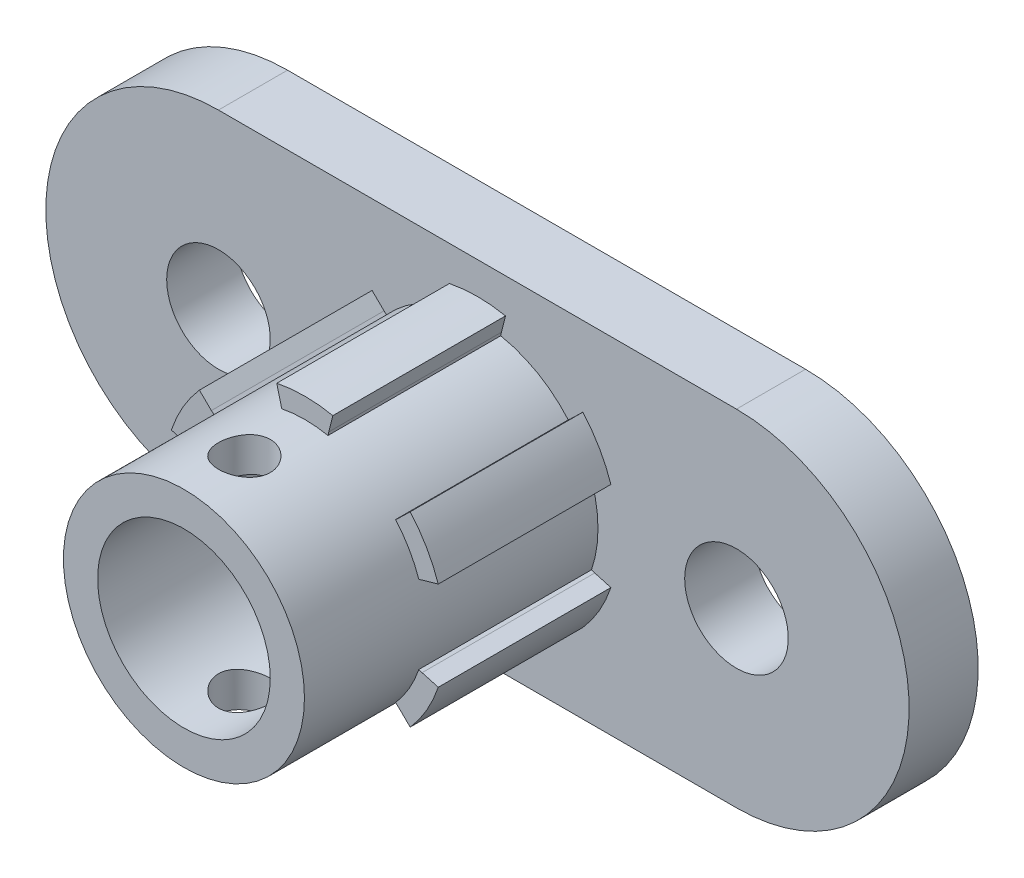
from build123d import *

# Parameters (mm, degrees)
BOSS_EXTRUDE1_DEPTH = 10
SKETCH4_R           = 3
BOSS_EXTRUDE2_DEPTH = 4
CUT_EXTRUDE2_DEPTH  = 10
SKETCH9_R           = 5
CUT_EXTRUDE3_DEPTH  = 15
SKETCH10_R          = 6.98
SKETCH10_R_2        = 5
BOSS_EXTRUDE3_DEPTH = 7
SKETCH11_R          = 1.5
CUT_EXTRUDE4_DEPTH  = 21


with BuildPart() as part:
    # Sketch3 → Boss-Extrude1 (new body)
    with BuildSketch(Plane.XY):
        with BuildLine():
            Line((-7.72865, 2.586593), (-6.793519, 2.323899))
            ThreePointArc((-6.793519, 2.323899), (-7.18, 0), (-6.793519, -2.323899))
            Line((-6.793519, -2.323899), (-7.72865, -2.586593))
            ThreePointArc((-7.72865, -2.586593), (-7.058107, -4.075), (-6.104381, -5.399911))
            Line((-6.104381, -5.399911), (-5.409315, -4.72141))
            ThreePointArc((-5.409315, -4.72141), (-3.59, -6.218062), (-1.384204, -7.045309))
            Line((-1.384204, -7.045309), (-1.62427, -7.986504))
            ThreePointArc((-1.62427, -7.986504), (0, -8.15), (1.62427, -7.986504))
            Line((1.62427, -7.986504), (1.384204, -7.045309))
            ThreePointArc((1.384204, -7.045309), (3.59, -6.218062), (5.409315, -4.72141))
            Line((5.409315, -4.72141), (6.104381, -5.399911))
            ThreePointArc((6.104381, -5.399911), (7.058107, -4.075), (7.72865, -2.586593))
            Line((7.72865, -2.586593), (6.793519, -2.323899))
            ThreePointArc((6.793519, -2.323899), (7.18, 0), (6.793519, 2.323899))
            Line((6.793519, 2.323899), (7.72865, 2.586593))
            ThreePointArc((7.72865, 2.586593), (7.058107, 4.075), (6.104381, 5.399911))
            Line((6.104381, 5.399911), (5.409315, 4.72141))
            ThreePointArc((5.409315, 4.72141), (3.59, 6.218062), (1.384204, 7.045309))
            Line((1.384204, 7.045309), (1.62427, 7.986504))
            ThreePointArc((1.62427, 7.986504), (0, 8.15), (-1.62427, 7.986504))
            Line((-1.62427, 7.986504), (-1.384204, 7.045309))
            ThreePointArc((-1.384204, 7.045309), (-3.59, 6.218062), (-5.409315, 4.72141))
            Line((-5.409315, 4.72141), (-6.104381, 5.399911))
            ThreePointArc((-6.104381, 5.399911), (-7.058107, 4.075), (-7.72865, 2.586593))
        make_face()
    extrude(amount=BOSS_EXTRUDE1_DEPTH)

    # Sketch4 → Boss-Extrude2 (add)
    with BuildSketch(Plane(origin=(0, 0, 0), x_dir=(-1, 0, 0), z_dir=(0, 0, -1))):
        with BuildLine():
            Line((-15, 10), (15, 10))
            ThreePointArc((15, 10), (25, 0), (15, -10))
            Line((15, -10), (-15, -10))
            ThreePointArc((-15, -10), (-25, 0), (-15, 10))
        make_face()
        with Locations((-15, 0)):
            Circle(SKETCH4_R, mode=Mode.SUBTRACT)
        with Locations((15, 0)):
            Circle(SKETCH4_R, mode=Mode.SUBTRACT)
    extrude(amount=BOSS_EXTRUDE2_DEPTH)

    # Sketch8 → Cut-Extrude2 (cut)
    with BuildSketch(Plane.XY.offset(10)):
        with BuildLine():
            Line((-5.409315, 4.72141), (-5.258637, 4.589895))
            ThreePointArc((-5.258637, 4.589895), (-3.49, 6.044857), (-1.345647, 6.849061))
            Line((-1.345647, 6.849061), (-1.384204, 7.045309))
            ThreePointArc((-1.384204, 7.045309), (-3.59, 6.218062), (-5.409315, 4.72141))
        make_face()
        with BuildLine():
            Line((5.409315, 4.72141), (5.258637, 4.589895))
            ThreePointArc((5.258637, 4.589895), (3.49, 6.044857), (1.345647, 6.849061))
            Line((1.345647, 6.849061), (1.384204, 7.045309))
            ThreePointArc((1.384204, 7.045309), (3.59, 6.218062), (5.409315, 4.72141))
        make_face()
        with BuildLine():
            Line((6.793519, -2.323899), (6.604284, -2.259166))
            ThreePointArc((6.604284, -2.259166), (6.98, 0), (6.604284, 2.259166))
            Line((6.604284, 2.259166), (6.793519, 2.323899))
            ThreePointArc((6.793519, 2.323899), (7.18, 0), (6.793519, -2.323899))
        make_face()
        with BuildLine():
            Line((1.384204, -7.045309), (1.345647, -6.849061))
            ThreePointArc((1.345647, -6.849061), (3.49, -6.044857), (5.258637, -4.589895))
            Line((5.258637, -4.589895), (5.409315, -4.72141))
            ThreePointArc((5.409315, -4.72141), (3.59, -6.218062), (1.384204, -7.045309))
        make_face()
        with BuildLine():
            Line((-5.409315, -4.72141), (-5.258637, -4.589895))
            ThreePointArc((-5.258637, -4.589895), (-3.49, -6.044857), (-1.345647, -6.849061))
            Line((-1.345647, -6.849061), (-1.384204, -7.045309))
            ThreePointArc((-1.384204, -7.045309), (-3.59, -6.218062), (-5.409315, -4.72141))
        make_face()
        with BuildLine():
            Line((-6.793519, 2.323899), (-6.604284, 2.259166))
            ThreePointArc((-6.604284, 2.259166), (-6.98, 0), (-6.604284, -2.259166))
            Line((-6.604284, -2.259166), (-6.793519, -2.323899))
            ThreePointArc((-6.793519, -2.323899), (-7.18, 0), (-6.793519, 2.323899))
        make_face()
    extrude(amount=-CUT_EXTRUDE2_DEPTH, mode=Mode.SUBTRACT)

    # Sketch9 → Cut-Extrude3 (cut, through all)
    with BuildSketch(Plane.XY.offset(10)):
        Circle(SKETCH9_R)
    extrude(amount=-CUT_EXTRUDE3_DEPTH, mode=Mode.SUBTRACT)

    # Sketch10 → Boss-Extrude3 (add)
    with BuildSketch(Plane.XY.offset(10)):
        Circle(SKETCH10_R)
        Circle(SKETCH10_R_2, mode=Mode.SUBTRACT)
    extrude(amount=BOSS_EXTRUDE3_DEPTH)

    # Sketch11 → Cut-Extrude4 (cut, through all)
    with BuildSketch(Plane(origin=(0, 10, 0), x_dir=(1, 0, 0), z_dir=(0, 1, 0))):
        with Locations((0, -13.5)):
            Circle(SKETCH11_R)
    extrude(amount=-CUT_EXTRUDE4_DEPTH, mode=Mode.SUBTRACT)


solid = part.part
